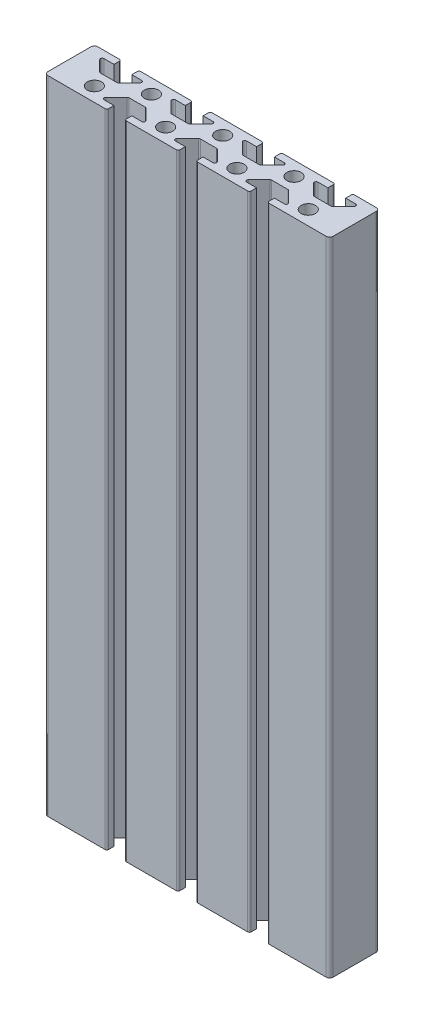
from build123d import *

# Parameters (mm, degrees)
SKETCH1_R           = 2
BOSS_EXTRUDE1_DEPTH = 180
FILLET1_R           = 0.5
FILLET2_R           = 0.5
FILLET3_R           = 1
SKETCH2_R           = 2.5
CUT_EXTRUDE2_DEPTH  = 230
SKETCH3_R           = 5.5
CUT_EXTRUDE3_DEPTH  = 7
SKETCH4_R           = 2.5
CUT_EXTRUDE4_DEPTH  = 7
SKETCH5_R           = 5.5
CUT_EXTRUDE5_DEPTH  = 7


with BuildPart() as part:
    # Sketch1 → Boss-Extrude1 (new body)
    with BuildSketch(Plane(origin=(0, 0, 0), x_dir=(1, 0, 0), z_dir=(0, 1, 0))):
        Polygon((67.5, 8), (63.5, 12), (67.5, 12), (67.5, 14), (52.5, 14), (52.5, 12), (56.5, 12), (52.5, 8), (47.5, 8), (43.5, 12), (47.5, 12), (47.5, 14), (32.5, 14), (32.5, 12), (36.5, 12), (32.5, 8), (27.5, 8), (23.5, 12), (27.5, 12), (27.5, 14), (12.5, 14), (12.5, 12), (16.5, 12), (12.5, 8), (7.5, 8), (3.5, 12), (7.5, 12), (7.5, 14), (0, 14), (0, 0), (17.5, 0), (17.5, 2), (13.5, 2), (17.5, 6), (22.5, 6), (26.5, 2), (22.5, 2), (22.5, 0), (37.5, 0), (37.5, 2), (33.5, 2), (37.5, 6), (42.5, 6), (46.5, 2), (42.5, 2), (42.5, 0), (57.5, 0), (57.5, 2), (53.5, 2), (57.5, 6), (62.5, 6), (66.5, 2), (62.5, 2), (62.5, 0), (80, 0), (80, 14), (72.5, 14), (72.5, 12), (76.5, 12), (72.5, 8), align=None)
        with Locations((10, 4)):
            Circle(SKETCH1_R, mode=Mode.SUBTRACT)
        with Locations((30, 4)):
            Circle(SKETCH1_R, mode=Mode.SUBTRACT)
        with Locations((50, 4)):
            Circle(SKETCH1_R, mode=Mode.SUBTRACT)
        with Locations((70, 4)):
            Circle(SKETCH1_R, mode=Mode.SUBTRACT)
        with Locations((20, 10)):
            Circle(SKETCH1_R, mode=Mode.SUBTRACT)
        with Locations((40, 10)):
            Circle(SKETCH1_R, mode=Mode.SUBTRACT)
        with Locations((60, 10)):
            Circle(SKETCH1_R, mode=Mode.SUBTRACT)
    extrude(amount=BOSS_EXTRUDE1_DEPTH)

    # Fillet1
    fillet1_edges = [part.edges().sort_by_distance(p)[0] for p in [
        (7.5, 90, -14),
        (3.5, 90, -12),
        (7.5, 90, -8),
        (12.5, 90, -8),
        (16.5, 90, -12),
        (12.5, 90, -14),
        (27.5, 90, -14),
        (23.5, 90, -12),
        (27.5, 90, -8),
        (32.5, 90, -8),
        (36.5, 90, -12),
        (32.5, 90, -14),
        (47.5, 90, -14),
        (43.5, 90, -12),
        (47.5, 90, -8),
        (52.5, 90, -8),
        (56.5, 90, -12),
        (52.5, 90, -14),
        (67.5, 90, -14),
        (63.5, 90, -12),
        (67.5, 90, -8),
        (72.5, 90, -8),
        (76.5, 90, -12),
        (72.5, 90, -14),
    ]]
    fillet(fillet1_edges, radius=FILLET1_R)

    # Fillet2
    fillet2_edges = [part.edges().sort_by_distance(p)[0] for p in [
        (26.5, 90, -2),
        (22.5, 90, -6),
        (17.5, 90, -6),
        (13.5, 90, -2),
        (17.5, 90, 0),
        (62.5, 90, 0),
        (66.5, 90, -2),
        (62.5, 90, -6),
        (57.5, 90, -6),
        (53.5, 90, -2),
        (57.5, 90, 0),
        (42.5, 90, 0),
        (46.5, 90, -2),
        (42.5, 90, -6),
        (37.5, 90, -6),
        (33.5, 90, -2),
        (37.5, 90, 0),
        (22.5, 90, 0),
    ]]
    fillet(fillet2_edges, radius=FILLET2_R)

    # Fillet3
    fillet3_edges = [part.edges().sort_by_distance(p)[0] for p in [
        (0, 90, 0),
        (0, 90, -14),
        (80, 90, -14),
        (80, 90, 0),
    ]]
    fillet(fillet3_edges, radius=FILLET3_R)

    # Sketch2 → Cut-Extrude2 (cut)
    with BuildSketch(Plane(origin=(0, 0, -14), x_dir=(-1, 0, 0), z_dir=(0, 0, -1))):
        with Locations((-40, 10)):
            Circle(SKETCH2_R)
    extrude(amount=-CUT_EXTRUDE2_DEPTH, mode=Mode.SUBTRACT)

    # Sketch3 → Cut-Extrude3 (cut)
    with BuildSketch(Plane(origin=(0, 0, -14), x_dir=(-1, 0, 0), z_dir=(0, 0, -1))):
        with Locations((-40, 10)):
            Circle(SKETCH3_R)
    extrude(amount=-CUT_EXTRUDE3_DEPTH, mode=Mode.SUBTRACT)

    # Sketch4 → Cut-Extrude4 (cut)
    with BuildSketch(Plane(origin=(0, 0, -14), x_dir=(-1, 0, 0), z_dir=(0, 0, -1))):
        with Locations((-40, 170)):
            Circle(SKETCH4_R)
    extrude(amount=-CUT_EXTRUDE4_DEPTH, mode=Mode.SUBTRACT)

    # Sketch5 → Cut-Extrude5 (cut)
    with BuildSketch(Plane(origin=(0, 0, -14), x_dir=(-1, 0, 0), z_dir=(0, 0, -1))):
        with Locations((-40, 170)):
            Circle(SKETCH5_R)
    extrude(amount=-CUT_EXTRUDE5_DEPTH, mode=Mode.SUBTRACT)


solid = part.part
